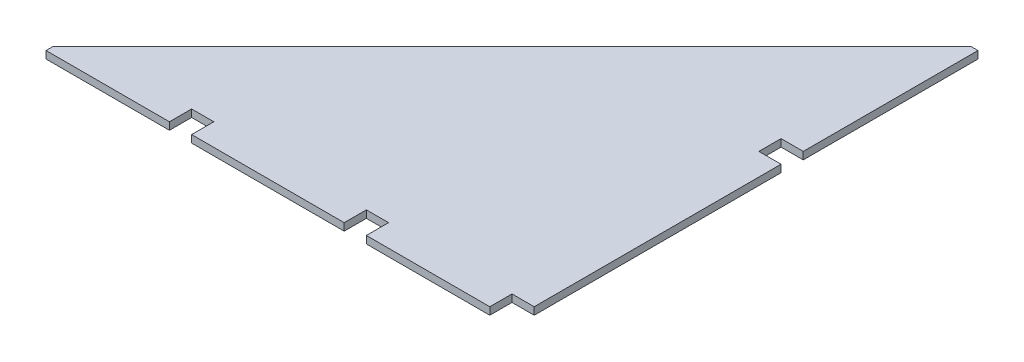
from build123d import *

# Parameters (mm, degrees)
BOSS_EXTRUDE1_DEPTH = 12.7


with BuildPart() as part:
    # Sketch1 → Boss-Extrude1 (new body)
    with BuildSketch(Plane(origin=(0, 0, 0), x_dir=(1, 0, 0), z_dir=(0, 1, 0))):
        Polygon((-38.1, 0), (-250, 0), (-250, 38.1), (-288.1, 38.1), (-288.1, 0), (-550, 0), (-550, 38.1), (-588.1, 38.1), (-588.1, 0), (-800, 0), (-800, 11.2), (-11.2, 800), (0, 800), (0, 500), (-38.1, 500), (-38.1, 461.9), (0, 461.9), (0, 38.1), (-38.1, 38.1), align=None)
    extrude(amount=BOSS_EXTRUDE1_DEPTH)


solid = part.part
